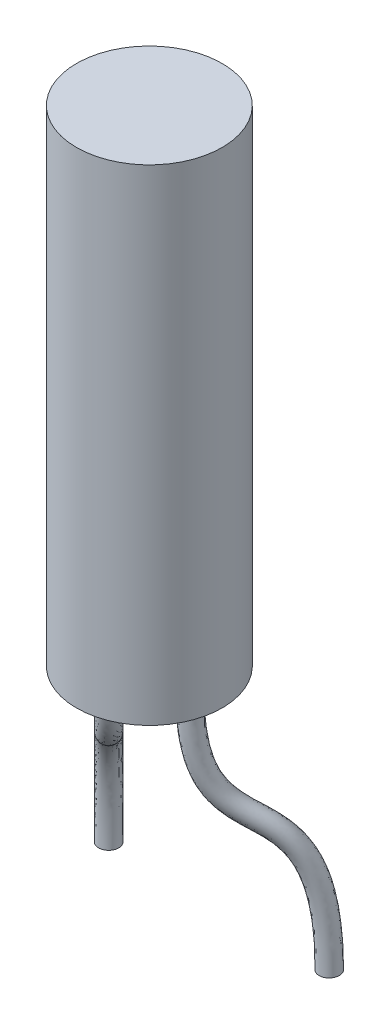
from build123d import *

# Parameters (mm, degrees)
SKETCH1_R           = 0.9
BOSS_EXTRUDE1_DEPTH = 6
SKETCH7_R           = 0.125
SKETCH8_R           = 0.125


with BuildPart() as part:
    # Sketch1 → Boss-Extrude1 (new body)
    with BuildSketch(Plane(origin=(0, 0, 0), x_dir=(1, 0, 0), z_dir=(0, 1, 0))):
        Circle(SKETCH1_R)
    extrude(amount=BOSS_EXTRUDE1_DEPTH)

    # Sweep1: sweep along a path in Sketch4
    with BuildLine() as sweep1_path:  # in the path sketch's own coordinates; laid on its plane below (add() does not lay a ready-made edge on the line's plane)
        add(Edge.make_bspline(
            [(0, -0.355), (2.024905843, -0.343321446), (0.641829723, -1.574292855), (3, -1.578751128)],
            knots=[0, 0, 0, 0, 1, 1, 1, 1], degree=3))
    # Sketch7 → Sweep1 (sweep)
    with BuildSketch(Plane.XZ):
        with Locations((-0.502045815, 0)):
            Circle(SKETCH7_R)
    sweep(path=Plane(origin=(-0.251022907, 0, 0.251022907), x_dir=(0, -1, 0), z_dir=(-0.7071067811865488, 0, 0.7071067811865464)) * sweep1_path.line)

    # Sweep2: sweep along a path in Sketch6
    with BuildLine() as sweep2_path:  # in the path sketch's own coordinates; laid on its plane below (add() does not lay a ready-made edge on the line's plane)
        add(Edge.make_bspline(
            [(0, -0.355), (2.024905843, -0.343321446), (0.641829723, -1.568079226), (3, -1.572537499)],
            knots=[0, 0, 0, 0, 1, 1, 1, 1], degree=3))
    # Sketch8 → Sweep2 (sweep)
    with BuildSketch(Plane.XZ):
        with Locations((0.502045815, 0)):
            Circle(SKETCH8_R)
    sweep(path=Plane(origin=(0.251022907, 0, 0.251022907), x_dir=(0, -1, 0), z_dir=(-0.7071067811865464, 0, -0.7071067811865488)) * sweep2_path.line)


solid = part.part
